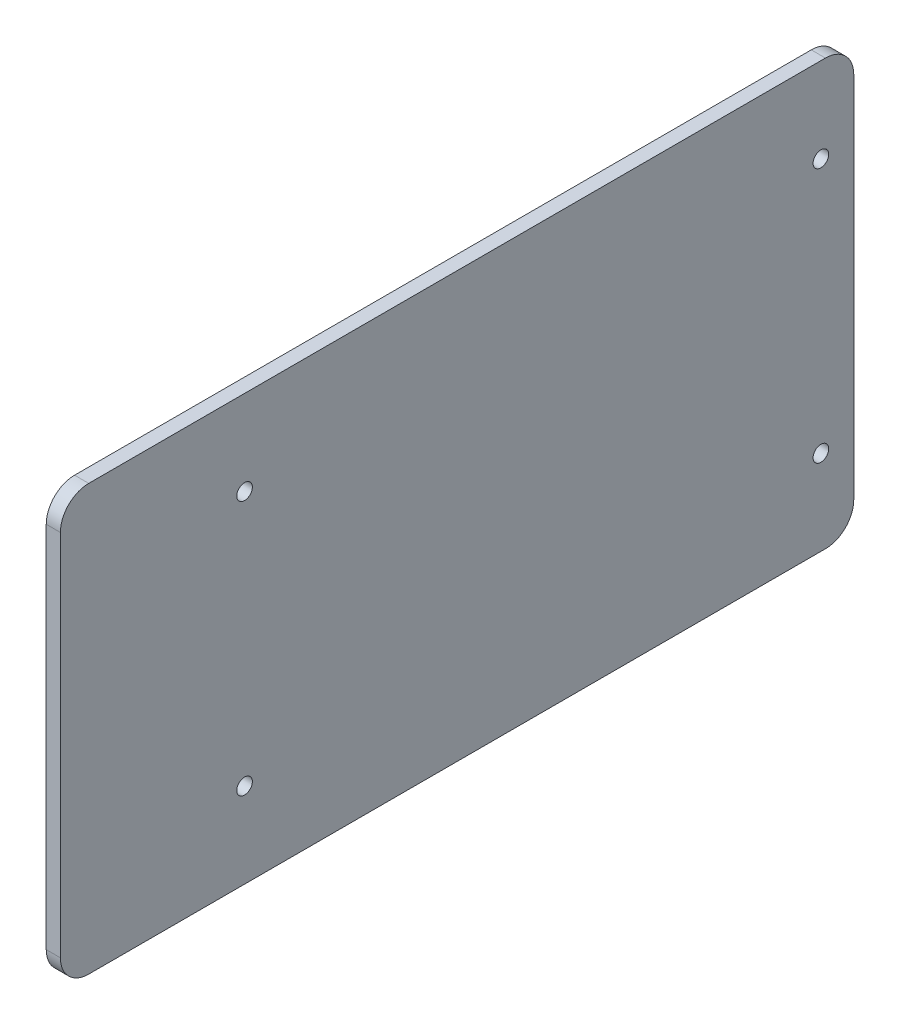
from build123d import *

# Parameters (mm, degrees)
DODANIE_WYCI_GNI_CIE1_DEPTH = 5
OTW_R_POD_RUB_M51_D         = 5.5
OTW_R_POD_RUB_M51_DEPTH     = 14
OTW_R_POD_RUB_M51_TIP       = 1.652366702
OTW_R_POD_RUB_M52_D         = 5.5
OTW_R_POD_RUB_M52_DEPTH     = 14
OTW_R_POD_RUB_M52_TIP       = 1.652366702


with BuildPart() as part:
    # Szkic1 → Dodanie-wyciągnięcie1 (new body)
    with BuildSketch(Plane(origin=(1037.6, 0, 0), x_dir=(0, 0, -1), z_dir=(1, 0, 0))):
        with BuildLine():
            Line((-892.51, 75), (-632.51, 75))
            ThreePointArc((-632.51, 75), (-625.438932188, 72.071067812), (-622.51, 65))
            Line((-622.51, 65), (-622.51, -65))
            ThreePointArc((-622.51, -65), (-625.438932188, -72.071067812), (-632.51, -75))
            Line((-632.51, -75), (-892.51, -75))
            ThreePointArc((-892.51, -75), (-899.581067812, -72.071067812), (-902.51, -65))
            Line((-902.51, -65), (-902.51, 65))
            ThreePointArc((-902.51, 65), (-899.581067812, 72.071067812), (-892.51, 75))
        make_face()
    extrude(amount=-DODANIE_WYCI_GNI_CIE1_DEPTH)

    # Otwór pod śrubę M51
    with Locations(Plane.ZY.offset(-1032.6)):
        with Locations((634.12, 45), (634.12, -45)):
            Hole(OTW_R_POD_RUB_M51_D / 2, depth=OTW_R_POD_RUB_M51_DEPTH)
            with Locations((0, 0, -(OTW_R_POD_RUB_M51_DEPTH + OTW_R_POD_RUB_M51_TIP / 2))):  # 118° drill point
                Cone(0, OTW_R_POD_RUB_M51_D / 2, OTW_R_POD_RUB_M51_TIP, mode=Mode.SUBTRACT)

    # Otwór pod śrubę M52
    with Locations(Plane.ZY.offset(-1032.6)):
        with Locations((837.51, 45), (837.51, -45)):
            Hole(OTW_R_POD_RUB_M52_D / 2, depth=OTW_R_POD_RUB_M52_DEPTH)
            with Locations((0, 0, -(OTW_R_POD_RUB_M52_DEPTH + OTW_R_POD_RUB_M52_TIP / 2))):  # 118° drill point
                Cone(0, OTW_R_POD_RUB_M52_D / 2, OTW_R_POD_RUB_M52_TIP, mode=Mode.SUBTRACT)


solid = part.part
